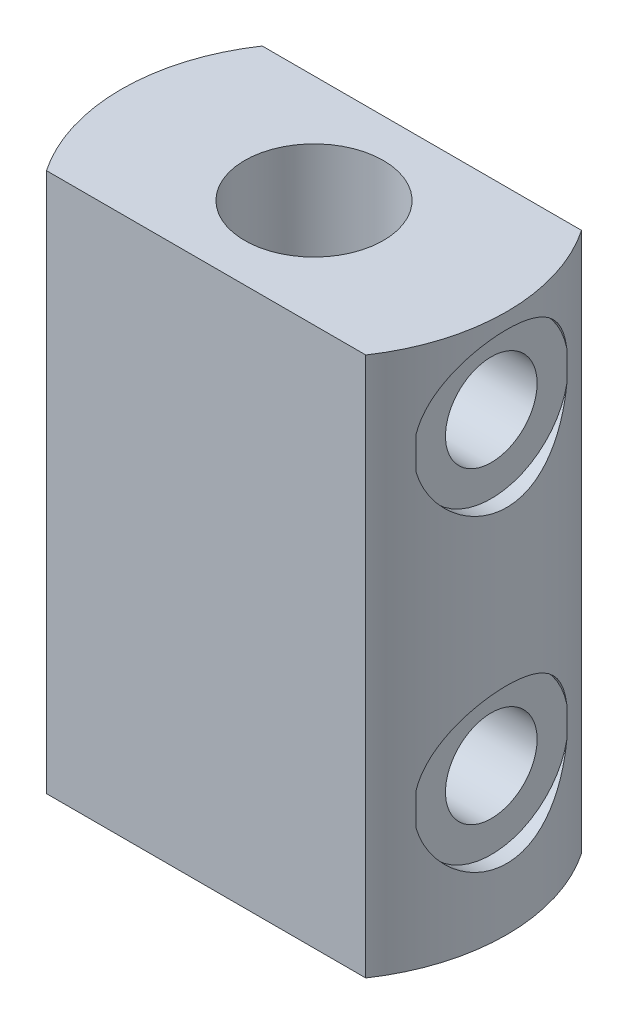
from build123d import *

# Parameters (mm, degrees)
FURO_ROSCADO_DE_1_4_18_NPSM1_REACH  = 69.594
FURO_ROSCADO_DE_1_4_18_NPSM1_BORE_R = 5.9436
FURO_ROSCADO_DE_1_4_18_NPSM2_REACH  = 82.554
FURO_ROSCADO_DE_1_4_18_NPSM2_BORE_R = 5.9436
ESBO_O4_R                           = 10
CORTE_EXTRUS_O1_DEPTH               = 2
ESBO_O6_R                           = 10
CORTE_EXTRUS_O2_DEPTH               = 2
CORTE_EXTRUS_O3_DEPTH               = 79.42193586


with BuildPart() as part:
    # Esboço1 → Revolução1 (revolve)
    with BuildSketch(Plane.XY, mode=Mode.PRIVATE) as revolu_o1_sk:
        Polygon((9, 32), (25, 32), (25, -38), (0, -38), (0, -34), (9, -34), align=None)
    revolve(revolu_o1_sk.sketch.rotate(Axis((0, 0, 0), (0, 1, 0)), 90), axis=Axis((0, 0, 0), (0, 1, 0)))

    # Furo roscado de 1/4-18 NPSM1 bore (on position points) → Furo roscado de 1/4-18 NPSM1 (cut, up to next)
    with BuildSketch(Plane(origin=(-25, 0, 0), x_dir=(0, 0, -1), z_dir=(-1, 0, 0)), mode=Mode.PRIVATE) as furo_roscado_de_1_4_18_npsm1_sk1:
        Circle(FURO_ROSCADO_DE_1_4_18_NPSM1_BORE_R)
    furo_roscado_de_1_4_18_npsm1_tool1 = extrude(furo_roscado_de_1_4_18_npsm1_sk1.sketch, amount=-FURO_ROSCADO_DE_1_4_18_NPSM1_REACH, mode=Mode.PRIVATE) & part.part
    add(furo_roscado_de_1_4_18_npsm1_tool1.solids().sort_by_distance((-25, 0, 0))[0], mode=Mode.SUBTRACT)

    # Furo roscado de 1/4-18 NPSM2 bore (on position points) → Furo roscado de 1/4-18 NPSM2 (cut, up to next)
    with BuildSketch(Plane(origin=(25, 20, 0), x_dir=(0, 0, 1), z_dir=(1, 0, 0)), mode=Mode.PRIVATE) as furo_roscado_de_1_4_18_npsm2_sk1:
        Circle(FURO_ROSCADO_DE_1_4_18_NPSM2_BORE_R)
    furo_roscado_de_1_4_18_npsm2_tool1 = extrude(furo_roscado_de_1_4_18_npsm2_sk1.sketch, amount=-FURO_ROSCADO_DE_1_4_18_NPSM2_REACH, mode=Mode.PRIVATE) & part.part
    # Furo roscado de 1/4-18 NPSM2 bore (on position points) → Furo roscado de 1/4-18 NPSM2 (cut, up to next)
    with BuildSketch(Plane(origin=(25, 20, 0), x_dir=(0, 0, 1), z_dir=(1, 0, 0)), mode=Mode.PRIVATE) as furo_roscado_de_1_4_18_npsm2_sk2:
        with Locations((0, 40)):
            Circle(FURO_ROSCADO_DE_1_4_18_NPSM2_BORE_R)
    furo_roscado_de_1_4_18_npsm2_tool2 = extrude(furo_roscado_de_1_4_18_npsm2_sk2.sketch, amount=-FURO_ROSCADO_DE_1_4_18_NPSM2_REACH, mode=Mode.PRIVATE) & part.part
    add(furo_roscado_de_1_4_18_npsm2_tool1.solids().sort_by_distance((25, 20, 0))[0], mode=Mode.SUBTRACT)
    add(furo_roscado_de_1_4_18_npsm2_tool2.solids().sort_by_distance((25, -20, 0))[0], mode=Mode.SUBTRACT)

    # Esboço4 → Corte-extrusão1 (cut)
    with BuildSketch(Plane(origin=(-25, 0, 0), x_dir=(0, 0, -1), z_dir=(1, 0, 0))):
        Circle(ESBO_O4_R)
    extrude(amount=CORTE_EXTRUS_O1_DEPTH, mode=Mode.SUBTRACT)

    # Esboço6 → Corte-extrusão2 (cut)
    with BuildSketch(Plane(origin=(25, 0, 0), x_dir=(0, 0, -1), z_dir=(1, 0, 0))):
        with Locations((0, 20)):
            Circle(ESBO_O6_R)
        with Locations((0, -20)):
            Circle(ESBO_O6_R)
    extrude(amount=-CORTE_EXTRUS_O2_DEPTH, mode=Mode.SUBTRACT)

    # Esboço7 → Corte-extrusão3 (cut, through all)
    with BuildSketch(Plane(origin=(0, 32, 0), x_dir=(1, 0, 0), z_dir=(0, 1, 0))):
        with BuildLine():
            Line((-20.712315177, 14), (20.712315177, 14))
            ThreePointArc((20.712315177, 14), (0, 25), (-20.712315177, 14))
        make_face()
        with BuildLine():
            Line((-20.712315177, -14), (20.712315177, -14))
            ThreePointArc((20.712315177, -14), (0, -25), (-20.712315177, -14))
        make_face()
    extrude(amount=-CORTE_EXTRUS_O3_DEPTH, mode=Mode.SUBTRACT)


solid = part.part
